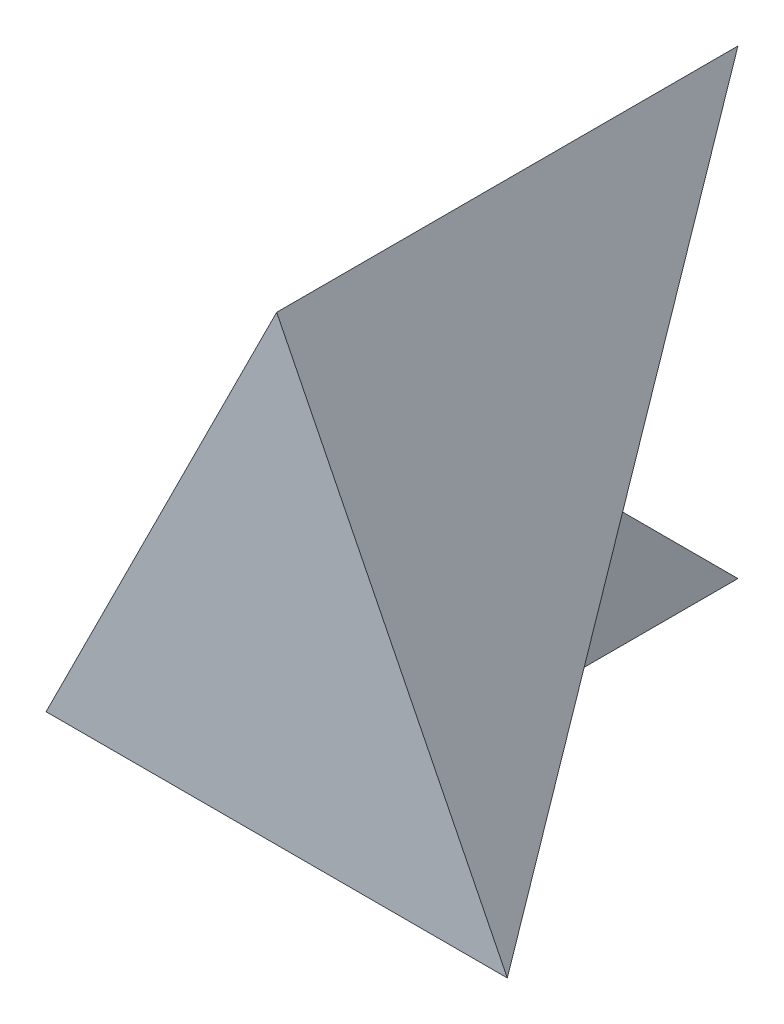
from build123d import *

# Parameters (mm, degrees)
SKETCH1_W           = 4
SKETCH1_H           = 4
BOSS_EXTRUDE1_DEPTH = 4
CUT_EXTRUDE1_DEPTH  = 2
CUT_EXTRUDE2_DEPTH  = 2
CUT_EXTRUDE3_DEPTH  = 10
CUT_EXTRUDE4_DEPTH  = 10


with BuildPart() as part:
    # Sketch1 → Boss-Extrude1 (new body)
    with BuildSketch(Plane(origin=(0, 0, 0), x_dir=(1, 0, 0), z_dir=(0, 1, 0))):
        Rectangle(SKETCH1_W, SKETCH1_H)
    extrude(amount=BOSS_EXTRUDE1_DEPTH)

    # Sketch2 → Cut-Extrude1 (cut)
    with BuildSketch(Plane.ZY.offset(2)):
        Polygon((2, 4), (-2, 0), (-2, 4), align=None)
    extrude(amount=-CUT_EXTRUDE1_DEPTH, mode=Mode.SUBTRACT)

    # Sketch3 → Cut-Extrude2 (cut)
    with BuildSketch(Plane(origin=(2, 0, 0), x_dir=(0, 0, -1), z_dir=(1, 0, 0))):
        Polygon((-2, 0), (2, 4), (2, 0), align=None)
    extrude(amount=-CUT_EXTRUDE2_DEPTH, mode=Mode.SUBTRACT)

    # Sketch4 → Cut-Extrude3 (cut)
    with BuildSketch(Plane.XY.offset(2)):
        Polygon((2, 0), (0, 4), (2, 4), align=None)
    extrude(amount=-CUT_EXTRUDE3_DEPTH, mode=Mode.SUBTRACT)

    # 3DSketch1 → Cut-Extrude4 (cut, along a direction that is not the sketch's normal)
    with BuildSketch(Plane(origin=(0, 0, -2), x_dir=(0, 0.7071067811865476, 0.7071067811865476), z_dir=(0.816496580927726, -0.408248290463863, 0.408248290463863))):
        Polygon((0, 0), (2.828427125, 3.464101615), (5.656854249, 0), align=None)
    extrude(amount=-CUT_EXTRUDE4_DEPTH, dir=(0, 0, 1), mode=Mode.SUBTRACT)


with BuildPart() as body_2:
    # of the pieces the cut leaves, the one that is kept (cut_extrude4_keep)
    add(part.part.solids().sort_by_distance((0, 0, 2))[0])


solid = body_2.part
